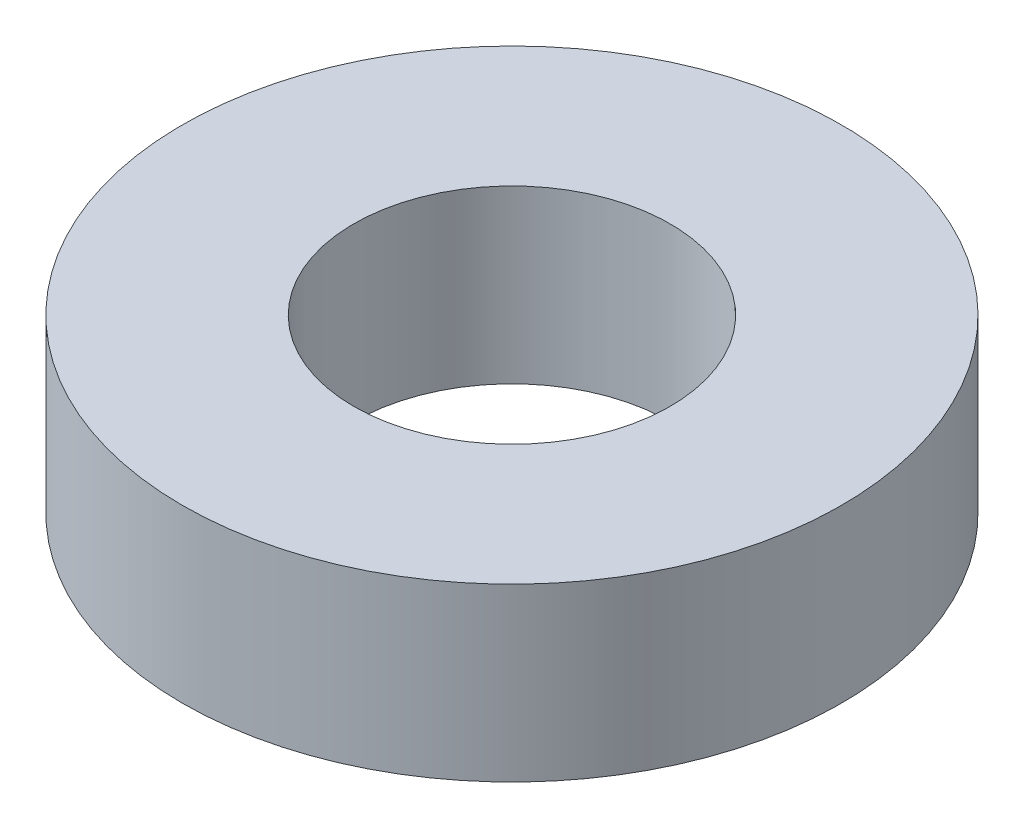
from build123d import *

# Parameters (mm, degrees)
SKETCH1_R           = 6.105769231
SKETCH1_R_2         = 2.930769231
BOSS_EXTRUDE1_DEPTH = 3.175


with BuildPart() as part:
    # Sketch1 → Boss-Extrude1 (new body)
    with BuildSketch(Plane(origin=(0, 0, 0), x_dir=(1, 0, 0), z_dir=(0, 1, 0))):
        Circle(SKETCH1_R)
        Circle(SKETCH1_R_2, mode=Mode.SUBTRACT)
    extrude(amount=BOSS_EXTRUDE1_DEPTH)


solid = part.part
